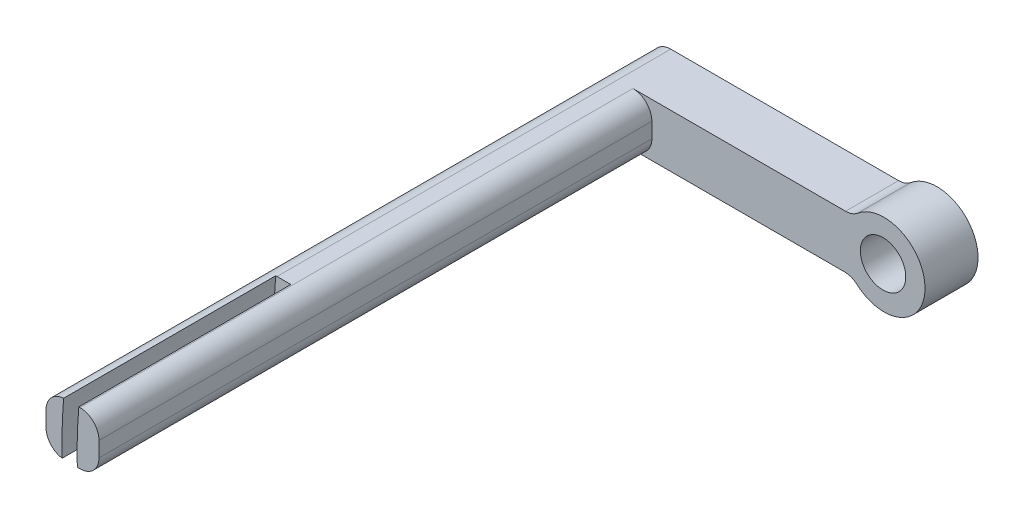
from build123d import *

# Parameters (mm, degrees)
BOSS_EXTRUDE1_DEPTH = 7
FILLET1_R           = 2.5
SKETCH2_R           = 5.410546581
BOSS_EXTRUDE2_DEPTH = 7
FILLET2_R           = 2.5
SKETCH3_R           = 3
CUT_EXTRUDE1_DEPTH  = 16
SKETCH4_R           = 63
SKETCH4_R_2         = 61
CUT_EXTRUDE2_DEPTH  = 28


with BuildPart() as part:
    # Sketch1 → Boss-Extrude1 (new body)
    with BuildSketch(Plane(origin=(0, 0, 0), x_dir=(1, 0, 0), z_dir=(0, 1, 0))):
        Polygon((-6.297256143, 55.195428384), (0.702743857, 55.195428384), (33.702743857, 55.195428384), (33.702743857, 48.195428384), (0.702743857, 48.195428384), (0.702743857, -24.804571616), (-6.297256143, -24.804571616), align=None)
    extrude(amount=BOSS_EXTRUDE1_DEPTH)

    # Fillet1
    fillet1_edges = [part.edges().sort_by_distance(p)[0] for p in [
        (-6.297256143, 7, -15.195428384),
        (0.702743857, 7, -11.695428384),
        (-6.297256143, 0, -15.195428384),
        (0.702743857, 0, -11.695428384),
    ]]
    fillet(fillet1_edges, radius=FILLET1_R)

    # Sketch2 → Boss-Extrude2 (add)
    with BuildSketch(Plane(origin=(0, 0, -55.195428384), x_dir=(-1, 0, 0), z_dir=(0, 0, -1))):
        with Locations((-31.362766576, 3.435192577)):
            Circle(SKETCH2_R)
    extrude(amount=-BOSS_EXTRUDE2_DEPTH)

    # Fillet2
    fillet2_edges = [part.edges().sort_by_distance(p)[0] for p in [
        (27.182639034, 0, -51.695428384),
        (27.2926115, 7, -51.695428384),
    ]]
    fillet(fillet2_edges, radius=FILLET2_R)

    # Sketch3 → Cut-Extrude1 (cut)
    with BuildSketch(Plane(origin=(0, 0, -55.195428384), x_dir=(-1, 0, 0), z_dir=(0, 0, -1))):
        with Locations((-31.229894895, 3.460516579)):
            Circle(SKETCH3_R)
    extrude(amount=-CUT_EXTRUDE1_DEPTH, mode=Mode.SUBTRACT)

    # Sketch4 → Cut-Extrude2 (cut)
    with BuildSketch(Plane.XY.offset(24.804571616)):
        with Locations((58.808648779, 1.743015897)):
            Circle(SKETCH4_R)
        with Locations((58.808648779, 1.743015897)):
            Circle(SKETCH4_R_2, mode=Mode.SUBTRACT)
    extrude(amount=-CUT_EXTRUDE2_DEPTH, mode=Mode.SUBTRACT)


solid = part.part
